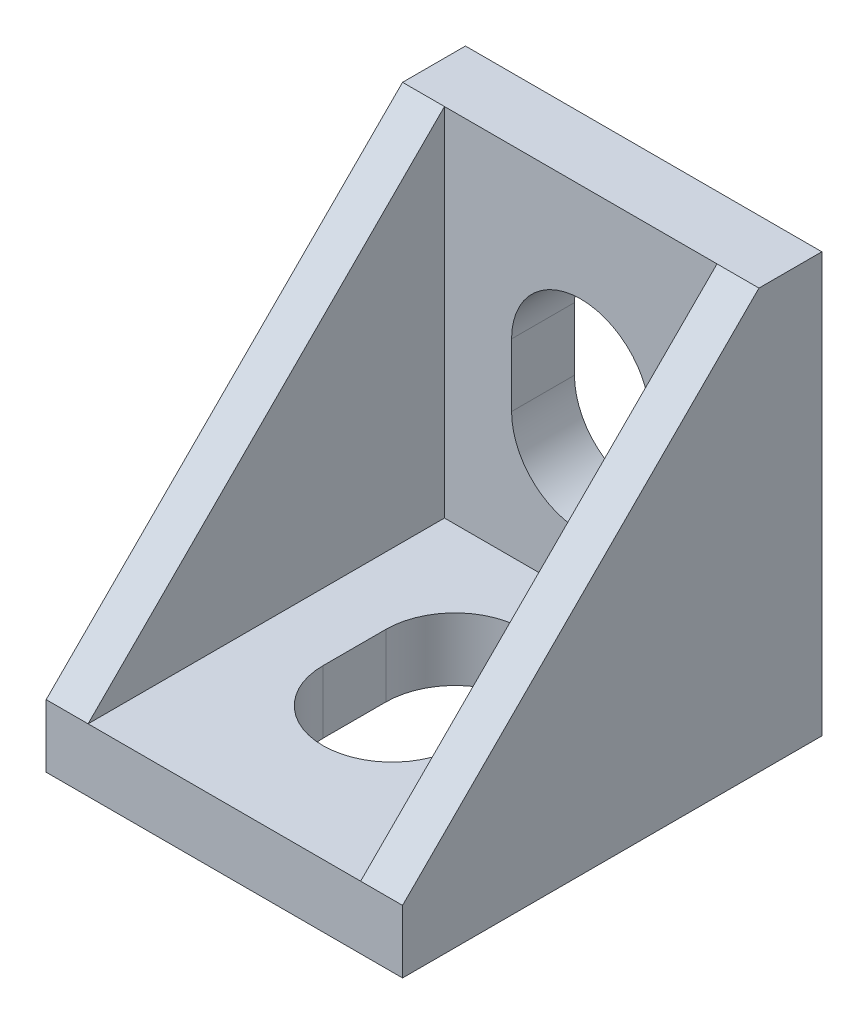
from build123d import *

# Parameters (mm, degrees)
SKETCH1_W           = 20
SKETCH1_H           = 20
BOSS_EXTRUDE1_DEPTH = 8.5
CUT_EXTRUDE1_DEPTH  = 34
SKETCH3_W           = 13
SKETCH3_H           = 17
CUT_EXTRUDE2_DEPTH  = 17
CUT_EXTRUDE4_DEPTH  = 28.590759323
CUT_EXTRUDE5_DEPTH  = 28.590759323
SKETCH7_W           = 4.5
SKETCH7_H           = 1.6
BOSS_EXTRUDE2_DEPTH = 1
SKETCH8_W           = 4.5
SKETCH8_H           = 1.6
BOSS_EXTRUDE3_DEPTH = 1


with BuildPart() as part:
    # Sketch1 → Boss-Extrude1 (new, symmetric)
    with BuildSketch(Plane(origin=(0, 0, 0), x_dir=(0, 0, -1), z_dir=(1, 0, 0))):
        with Locations((-10, 10)):
            Rectangle(SKETCH1_W, SKETCH1_H)
    extrude(amount=BOSS_EXTRUDE1_DEPTH, both=True)

    # Sketch2 → Cut-Extrude1 (cut, through all)
    with BuildSketch(Plane.ZY.offset(8.5)):
        Polygon((20, 20), (3, 20), (20, 3), align=None)
    extrude(amount=-CUT_EXTRUDE1_DEPTH, mode=Mode.SUBTRACT)

    # Sketch3 → Cut-Extrude2 (cut)
    with BuildSketch(Plane(origin=(0, 20, 0), x_dir=(1, 0, 0), z_dir=(0, 1, 0))):
        with Locations((0, -11.5)):
            Rectangle(SKETCH3_W, SKETCH3_H)
    extrude(amount=-CUT_EXTRUDE2_DEPTH, mode=Mode.SUBTRACT)

    # Sketch5 → Cut-Extrude4 (cut, through all)
    with BuildSketch(Plane.XY.offset(3)):
        with BuildLine():
            Line((-3.3, 9), (-3.3, 12))
            ThreePointArc((-3.3, 12), (0, 15.3), (3.3, 12))
            Line((3.3, 12), (3.3, 9))
            ThreePointArc((3.3, 9), (0, 5.7), (-3.3, 9))
        make_face()
    extrude(amount=-CUT_EXTRUDE4_DEPTH, mode=Mode.SUBTRACT)

    # Sketch6 → Cut-Extrude5 (cut, through all)
    with BuildSketch(Plane(origin=(0, 3, 0), x_dir=(1, 0, 0), z_dir=(0, 1, 0))):
        with BuildLine():
            Line((3.3, -9), (3.3, -12))
            ThreePointArc((3.3, -12), (0, -15.3), (-3.3, -12))
            Line((-3.3, -12), (-3.3, -9))
            ThreePointArc((-3.3, -9), (0, -5.7), (3.3, -9))
        make_face()
    extrude(amount=-CUT_EXTRUDE5_DEPTH, mode=Mode.SUBTRACT)

    # Sketch7 → Boss-Extrude2 (add)
    with BuildSketch(Plane(origin=(0, 0, 0), x_dir=(-1, 0, 0), z_dir=(0, 0, -1))):
        with Locations((0, 17.8)):
            Rectangle(SKETCH7_W, SKETCH7_H)
        with Locations((0, 2.2)):
            Rectangle(SKETCH7_W, SKETCH7_H)
    extrude(amount=BOSS_EXTRUDE2_DEPTH)

    # Sketch8 → Boss-Extrude3 (add)
    with BuildSketch(Plane.XZ):
        with Locations((0, 17.8)):
            Rectangle(SKETCH8_W, SKETCH8_H)
        with Locations((0, 2.2)):
            Rectangle(SKETCH8_W, SKETCH8_H)
    extrude(amount=BOSS_EXTRUDE3_DEPTH)


solid = part.part
